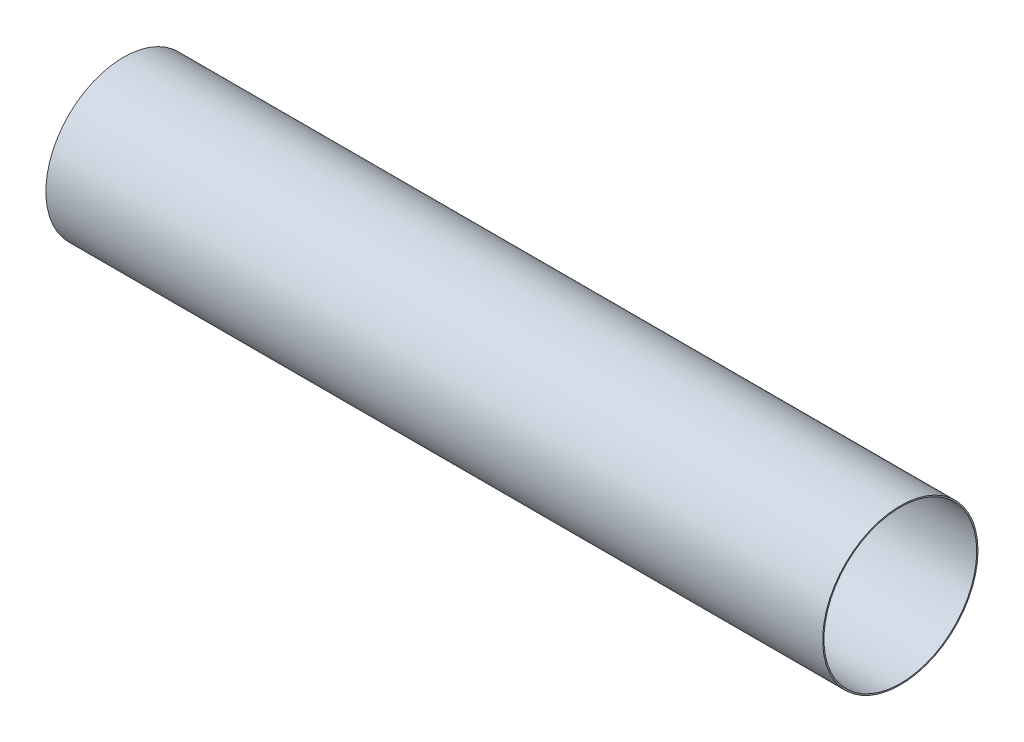
from build123d import *

# Parameters (mm, degrees)
SKETCH2_R           = 76.2
SKETCH2_R_2         = 74.93
BOSS_EXTRUDE1_DEPTH = 381


with BuildPart() as part:
    # Sketch2 → Boss-Extrude1 (new body, symmetric)
    with BuildSketch(Plane(origin=(0, 0, 0), x_dir=(0, 0, -1), z_dir=(1, 0, 0))):
        Circle(SKETCH2_R)
        Circle(SKETCH2_R_2, mode=Mode.SUBTRACT)
    extrude(amount=BOSS_EXTRUDE1_DEPTH, both=True)


solid = part.part
